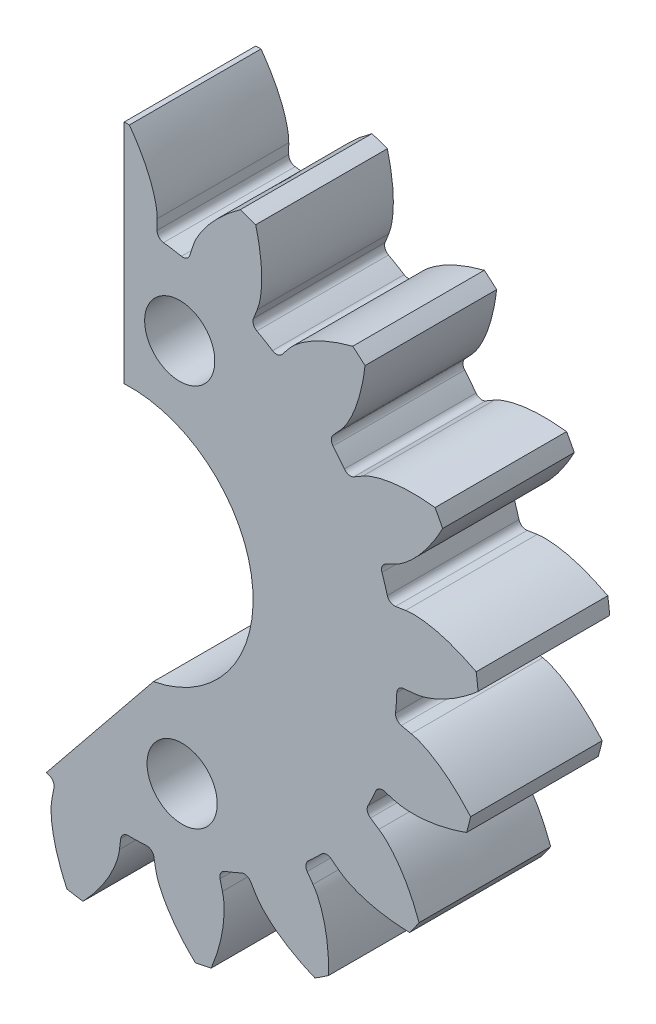
from build123d import *

# Parameters (mm, degrees)
SKETCH1_R                                           = 1.5
BOSS_EXTRUDE1_DEPTH                                 = 4.5
CUT_EXTRUDE1_DEPTH                                  = 5.5000001
CSK_FOR_M2_COUNTERSUNK_FLAT_HEAD_SCREW1_D           = 2.4
CSK_FOR_M2_COUNTERSUNK_FLAT_HEAD_SCREW1_DEPTH       = 10
CSK_FOR_M2_COUNTERSUNK_FLAT_HEAD_SCREW1_CSINK_D     = 4.4
CSK_FOR_M2_COUNTERSUNK_FLAT_HEAD_SCREW1_CSINK_ANGLE = 90
CSK_FOR_M2_COUNTERSUNK_FLAT_HEAD_SCREW1_TIP         = 0.721032743


with BuildPart() as part:
    # Sketch1 → Boss-Extrude1 (new body)
    with BuildSketch(Plane.XY):
        with BuildLine():
            Line((2.142690816, 9.446385822), (2.036760212, 9.116523343))
            ThreePointArc((2.036760212, 9.116523343), (1.925215556, 8.976884922), (1.749077663, 8.946610489))
            ThreePointArc((1.749077663, 8.946610489), (1.443445404, 9.000976463), (1.136139278, 9.044904613))
            ThreePointArc((1.136139278, 9.044904613), (0.978300237, 9.128737399), (0.916012393, 9.296252542))
            Line((0.916012393, 9.296252542), (0.918538131, 9.642697586))
            add(Edge.make_bspline(
                [(0.918538131, 9.642697586), (0.920074647, 9.853455045), (0.756738592, 10.686258414), (0.336577813, 11.434986659), (-0.030409782, 11.94504001)],
                knots=[0, 0, 0, 0, 0.250058326, 1, 1, 1, 1], degree=3))
            ThreePointArc((-0.030409782, 11.94504001), (-0.308005832, 11.941107068), (-0.585435504, 11.93072382))
            add(Edge.make_bspline(
                [(-0.585435504, 11.93072382), (-0.924729077, 11.407724954), (-1.308534817, 10.639195503), (-1.429406641, 9.798416791), (-1.414428472, 9.582521648)],
                knots=[-0.008484668, -0.008484668, -0.008484668, -0.008484668, 0.741457006, 1, 1, 1, 1], degree=3))
            Line((-1.414428472, 9.582521648), (-1.394045746, 9.236667499))
            ThreePointArc((-1.394045746, 9.236667499), (-1.447614825, 9.066163972), (-1.600922132, 8.974305558))
            ThreePointArc((-1.600922132, 8.974305558), (-1.905554981, 8.914593212), (-2.207978087, 8.844543215))
            ThreePointArc((-2.207978087, 8.844543215), (-2.385442505, 8.865696922), (-2.50403764, 8.999399176))
            Line((-2.50403764, 8.999399176), (-2.626832843, 9.32336196))
            add(Edge.make_bspline(
                [(-2.626832843, 9.32336196), (-2.701534461, 9.520442492), (-3.154684073, 10.238004717), (-3.81694417, 10.784393433), (-4.343402434, 11.127432808)],
                knots=[0, 0, 0, 0, 0.250058326, 1, 1, 1, 1], degree=3))
            ThreePointArc((-4.343402434, 11.127432808), (-4.600832298, 11.023486189), (-4.855776901, 10.913584942))
            add(Edge.make_bspline(
                [(-4.855776901, 10.913584942), (-4.983229754, 10.303336047), (-5.063493088, 9.448057053), (-4.872478404, 8.620390313), (-4.780521357, 8.424484826)],
                knots=[-0.008484668, -0.008484668, -0.008484668, -0.008484668, 0.741457006, 1, 1, 1, 1], degree=3))
            Line((-4.780521357, 8.424484826), (-4.636578102, 8.109348527))
            ThreePointArc((-4.636578102, 8.109348527), (-4.624936802, 7.93100734), (-4.734708522, 7.789970933))
            ThreePointArc((-4.734708522, 7.789970933), (-4.997199607, 7.62424475), (-5.253895777, 7.449677247))
            ThreePointArc((-5.253895777, 7.449677247), (-5.427018018, 7.405294949), (-5.585903513, 7.487127083))
            Line((-5.585903513, 7.487127083), (-5.817435487, 7.74485464))
            add(Edge.make_bspline(
                [(-5.817435487, 7.74485464), (-5.95828637, 7.901641426), (-6.640049173, 8.407051753), (-7.454966693, 8.677308116), (-8.069794519, 8.807004146)],
                knots=[0, 0, 0, 0, 0.250058326, 1, 1, 1, 1], degree=3))
            ThreePointArc((-8.069794519, 8.807004146), (-8.272290869, 8.617082417), (-8.470318721, 8.422505943))
            add(Edge.make_bspline(
                [(-8.470318721, 8.422505943), (-8.368717639, 7.807424515), (-8.13459856, 6.980906144), (-7.65749496, 6.278132356), (-7.500978342, 6.128674647)],
                knots=[-0.008484668, -0.008484668, -0.008484668, -0.008484668, 0.741457006, 1, 1, 1, 1], degree=3))
            Line((-7.500978342, 6.128674647), (-7.252914893, 5.886817101))
            ThreePointArc((-7.252914893, 5.886817101), (-7.177635437, 5.724724219), (-7.22904629, 5.553557567))
            ThreePointArc((-7.22904629, 5.553557567), (-7.413944735, 5.304199787), (-7.59024573, 5.048691086))
            ThreePointArc((-7.59024573, 5.048691086), (-7.735644677, 4.944766859), (-7.913362165, 4.963676991))
            Line((-7.913362165, 4.963676991), (-8.222361232, 5.120361784))
            add(Edge.make_bspline(
                [(-8.222361232, 5.120361784), (-8.410338689, 5.2156799), (-9.228638839, 5.440679864), (-10.086154654, 5.398304255), (-10.706316137, 5.297140773)],
                knots=[0, 0, 0, 0, 0.250058326, 1, 1, 1, 1], degree=3))
            ThreePointArc((-10.706316137, 5.297140773), (-10.826530719, 5.046893916), (-10.940897062, 4.793920846))
            add(Edge.make_bspline(
                [(-10.940897062, 4.793920846), (-10.623963835, 4.25707704), (-10.107081422, 3.570945177), (-9.40832439, 3.087977836), (-9.208386639, 3.005152997)],
                knots=[-0.008484668, -0.008484668, -0.008484668, -0.008484668, 0.741457006, 1, 1, 1, 1], degree=3))
            Line((-9.208386639, 3.005152997), (-8.889705338, 2.869238405))
            ThreePointArc((-8.889705338, 2.869238405), (-8.760954633, 2.745285371), (-8.7470613, 2.567105479))
            ThreePointArc((-8.7470613, 2.567105479), (-8.829395545, 2.267793252), (-8.901490937, 1.965851218))
            ThreePointArc((-8.901490937, 1.965851218), (-8.999529656, 1.816420605), (-9.172077407, 1.769854816))
            Line((-9.172077407, 1.769854816), (-9.516811531, 1.804335697))
            add(Edge.make_bspline(
                [(-9.516811531, 1.804335697), (-9.726528165, 1.825311903), (-10.570849691, 1.739514011), (-11.35515154, 1.390229491), (-11.896890436, 1.071869186)],
                knots=[0, 0, 0, 0, 0.250058326, 1, 1, 1, 1], degree=3))
            ThreePointArc((-11.896890436, 1.071869186), (-11.918587603, 0.795094426), (-11.933846629, 0.517890175))
            add(Edge.make_bspline(
                [(-11.933846629, 0.517890175), (-11.444384845, 0.131787721), (-10.714546932, -0.321291723), (-9.888507478, -0.519225201), (-9.672151294, -0.524231217)],
                knots=[-0.008484668, -0.008484668, -0.008484668, -0.008484668, 0.741457006, 1, 1, 1, 1], degree=3))
            Line((-9.672151294, -0.524231217), (-9.325891817, -0.535846836))
            ThreePointArc((-9.325891817, -0.535846836), (-9.16105836, -0.604919479), (-9.083737211, -0.766048429))
            ThreePointArc((-9.083737211, -0.766048429), (-9.052387561, -1.074891329), (-9.010540469, -1.382487749))
            ThreePointArc((-9.010540469, -1.382487749), (-9.047978288, -1.557243317), (-9.19205277, -1.662996058))
            Line((-9.19205277, -1.662996058), (-9.525963699, -1.755375925))
            add(Edge.make_bspline(
                [(-9.525963699, -1.755375925), (-9.729096116, -1.811574581), (-10.485408718, -2.196582847), (-11.090572289, -2.805603469), (-11.480723759, -3.298164274)],
                knots=[0, 0, 0, 0, 0.250058326, 1, 1, 1, 1], degree=3))
            ThreePointArc((-11.480723759, -3.298164274), (-11.400973189, -3.564086973), (-11.315064081, -3.828084435))
            add(Edge.make_bspline(
                [(-11.315064081, -3.828084435), (-10.719178266, -4.01130026), (-9.874953507, -4.170136395), (-9.033192836, -4.056303998), (-8.829638322, -3.982815101)],
                knots=[-0.008484668, -0.008484668, -0.008484668, -0.008484668, 0.741457006, 1, 1, 1, 1], degree=3))
            Line((-8.829638322, -3.982815101), (-8.50256493, -3.868562992))
            ThreePointArc((-8.50256493, -3.868562992), (-8.323910392, -3.873426601), (-8.193604078, -3.995743252))
            ThreePointArc((-8.193604078, -3.995743252), (-8.052804476, -4.272405879), (-7.902666581, -4.544114086))
            ThreePointArc((-7.902666581, -4.544114086), (-7.874447315, -4.7205929), (-7.970590473, -4.8712501))
            Line((-7.970590473, -4.8712501), (-8.248581684, -5.078014301))
            add(Edge.make_bspline(
                [(-8.248581684, -5.078014301), (-8.417695725, -5.20379788), (-8.983855196, -5.836019021), (-9.328149796, -6.622524135), (-9.514021721, -7.222762373)],
                knots=[0, 0, 0, 0, 0.250058326, 1, 1, 1, 1], degree=3))
            ThreePointArc((-9.514021721, -7.222762373), (-9.34359417, -7.441918676), (-9.16811943, -7.657055029))
            add(Edge.make_bspline(
                [(-9.16811943, -7.657055029), (-8.546287266, -7.612639914), (-7.701692893, -7.45578104), (-6.957895448, -7.045556464), (-6.794633768, -6.903497736)],
                knots=[-0.008484668, -0.008484668, -0.008484668, -0.008484668, 0.741457006, 1, 1, 1, 1], degree=3))
            Line((-6.794633768, -6.903497736), (-6.530919535, -6.678808281))
            ThreePointArc((-6.530919535, -6.678808281), (-6.362572202, -6.618805997), (-6.196879311, -6.685790808))
            ThreePointArc((-6.196879311, -6.685790808), (-5.965645524, -6.892908341), (-5.727493781, -7.092032636))
            ThreePointArc((-5.727493781, -7.092032636), (-5.637428599, -7.246400254), (-5.672655765, -7.421614824))
            Line((-5.672655765, -7.421614824), (-5.857183005, -7.714838707))
            add(Edge.make_bspline(
                [(-5.857183005, -7.714838707), (-5.969438883, -7.893219439), (-6.268982248, -8.687268487), (-6.305908984, -9.545036219), (-6.26239833, -10.171886391)],
                knots=[0, 0, 0, 0, 0.250058326, 1, 1, 1, 1], degree=3))
            ThreePointArc((-6.26239833, -10.171886391), (-6.024310985, -10.314678025), (-5.782969448, -10.451897912))
            add(Edge.make_bspline(
                [(-5.782969448, -10.451897912), (-5.219172814, -10.185850364), (-4.488275976, -9.734481141), (-3.942895724, -9.083267488), (-3.841976273, -8.891824748)],
                knots=[-0.008484668, -0.008484668, -0.008484668, -0.008484668, 0.741457006, 1, 1, 1, 1], degree=3))
            Line((-3.841976273, -8.891824748), (-3.677237268, -8.587043502))
            ThreePointArc((-3.677237268, -8.587043502), (-3.541933379, -8.470278967), (-3.363231656, -8.472885267))
            ThreePointArc((-3.363231656, -8.472885267), (-3.072793087, -8.582485337), (-2.778791209, -8.682132879))
            ThreePointArc((-2.778791209, -8.682132879), (-2.639043912, -8.7935411), (-2.608597463, -8.969649341))
            Line((-2.608597463, -8.969649341), (-2.674739306, -9.309731396))
            add(Edge.make_bspline(
                [(-2.674739306, -9.309731396), (-2.714976241, -9.516617976), (-2.70744851, -10.365254206), (-2.432020221, -11.178438271), (-2.165003344, -11.747240788)],
                knots=[0, 0, 0, 0, 0.250058326, 1, 1, 1, 1], degree=3))
            ThreePointArc((-2.165003344, -11.747240788), (-1.891411218, -11.794382951), (-1.616797397, -11.835154067))
            add(Edge.make_bspline(
                [(-1.616797397, -11.835154067), (-1.187180152, -11.38340528), (-0.668692519, -10.698485624), (-0.395386084, -9.894232906), (-0.370438593, -9.679261556)],
                knots=[-0.008484668, -0.008484668, -0.008484668, -0.008484668, 0.741457006, 1, 1, 1, 1], degree=3))
            Line((-0.370438593, -9.679261556), (-0.326923731, -9.335550916))
            ThreePointArc((-0.326923731, -9.335550916), (-0.242936827, -9.177793828), (-0.075360929, -9.115669622))
            ThreePointArc((-0.075360929, -9.115669622), (0.235057082, -9.112950131), (0.545202514, -9.099662968))
            ThreePointArc((0.545202514, -9.099662968), (0.715758279, -9.153065494), (0.807766381, -9.306283012))
            Line((0.807766381, -9.306283012), (0.868942758, -9.647293274))
            add(Edge.make_bspline(
                [(0.868942758, -9.647293274), (0.906158986, -9.854744521), (1.219741152, -10.643354909), (1.770326349, -11.302130292), (2.22478734, -11.736065222)],
                knots=[0, 0, 0, 0, 0.250058326, 1, 1, 1, 1], degree=3))
            ThreePointArc((2.22478734, -11.736065222), (2.496934113, -11.681191105), (2.767732101, -11.620007083))
            add(Edge.make_bspline(
                [(2.767732101, -11.620007083), (3.005147767, -11.043568236), (3.241201568, -10.217600341), (3.205522637, -9.368927344), (3.151128871, -9.159460457)],
                knots=[-0.008484668, -0.008484668, -0.008484668, -0.008484668, 0.741457006, 1, 1, 1, 1], degree=3))
            Line((3.151128871, -9.159460457), (3.067542667, -8.823240448))
            ThreePointArc((3.067542667, -8.823240448), (3.08886969, -8.645796776), (3.222687709, -8.527332282))
            ThreePointArc((3.222687709, -8.527332282), (3.511161491, -8.412660513), (3.795563616, -8.288233151))
            ThreePointArc((3.795563616, -8.288233151), (3.973893348, -8.276417674), (4.115036899, -8.386051594))
            Line((4.115036899, -8.386051594), (4.295269287, -8.681934737))
            add(Edge.make_bspline(
                [(4.295269287, -8.681934737), (4.40491242, -8.861933212), (4.982198012, -9.484011554), (5.733580536, -9.899406991), (6.314108166, -10.139869016)],
                knots=[0, 0, 0, 0, 0.250058326, 1, 1, 1, 1], degree=3))
            ThreePointArc((6.314108166, -10.139869016), (6.548054657, -9.990389672), (6.778464043, -9.835513755))
            add(Edge.make_bspline(
                [(6.778464043, -9.835513755), (6.791613828, -9.212236107), (6.713353424, -8.356771514), (6.373507764, -7.578296229), (6.247118921, -7.402623469)],
                knots=[-0.008484668, -0.008484668, -0.008484668, -0.008484668, 0.741457006, 1, 1, 1, 1], degree=3))
            Line((6.247118921, -7.402623469), (6.047720431, -7.119302467))
            ThreePointArc((6.047720431, -7.119302467), (6.003507239, -6.946136961), (6.085494515, -6.787331466))
            ThreePointArc((6.085494515, -6.787331466), (6.313064084, -6.576194476), (6.53331282, -6.357431519))
            ThreePointArc((6.53331282, -6.357431519), (6.6953321, -6.281993786), (6.866548882, -6.33323744))
            Line((6.866548882, -6.33323744), (7.141495898, -6.544032806))
            add(Edge.make_bspline(
                [(7.141495898, -6.544032806), (7.308758024, -6.672268717), (8.071781424, -7.043799887), (8.9224829, -7.159713921), (9.550673697, -7.174227313)],
                knots=[0, 0, 0, 0, 0.250058326, 1, 1, 1, 1], degree=3))
            ThreePointArc((9.550673697, -7.174227313), (9.714824136, -6.950330756), (9.873726855, -6.722679793))
            add(Edge.make_bspline(
                [(9.873726855, -6.722679793), (9.660834808, -6.136740445), (9.278829699, -5.367314387), (8.68071535, -4.764174216), (8.499400943, -4.646021162)],
                knots=[-0.008484668, -0.008484668, -0.008484668, -0.008484668, 0.741457006, 1, 1, 1, 1], degree=3))
            Line((8.499400943, -4.646021162), (8.211120038, -4.453863238))
            ThreePointArc((8.211120038, -4.453863238), (8.107337868, -4.30836286), (8.126421565, -4.130663926))
            ThreePointArc((8.126421565, -4.130663926), (8.262352391, -3.851576936), (8.388701925, -3.568023533))
            ThreePointArc((8.388701925, -3.568023533), (8.512529152, -3.439151827), (8.69069539, -3.425084476))
            Line((8.69069539, -3.425084476), (9.023223916, -3.522322983))
            add(Edge.make_bspline(
                [(9.023223916, -3.522322983), (9.225515358, -3.58147736), (10.071226027, -3.652284013), (10.906354508, -3.453061812), (11.497367823, -3.239666457)],
                knots=[0, 0, 0, 0, 0.250058326, 1, 1, 1, 1], degree=3))
            ThreePointArc((11.497367823, -3.239666457), (11.569552783, -2.971591157), (11.635488142, -2.701910674))
            add(Edge.make_bspline(
                [(11.635488142, -2.701910674), (11.225306515, -2.232443981), (10.591148608, -1.652971712), (9.815544227, -1.306624075), (9.603791772, -1.261947952)],
                knots=[-0.008484668, -0.008484668, -0.008484668, -0.008484668, 0.741457006, 1, 1, 1, 1], degree=3))
            Line((9.603791772, -1.261947952), (9.265562385, -1.186905099))
            ThreePointArc((9.265562385, -1.186905099), (9.116227595, -1.088720481), (9.069830353, -0.916127333))
            ThreePointArc((9.069830353, -0.916127333), (9.095764224, -0.606782588), (9.111150352, -0.296734198))
            ThreePointArc((9.111150352, -0.296734198), (9.180061972, -0.131833357), (9.341115328, -0.054354874))
            Line((9.341115328, -0.054354874), (9.686315544, -0.024903923))
            add(Edge.make_bspline(
                [(9.686315544, -0.024903923), (9.896315722, -0.006987639), (10.710495748, 0.232493054), (11.417262505, 0.719945428), (11.891278715, 1.132429305)],
                knots=[0, 0, 0, 0, 0.250058326, 1, 1, 1, 1], degree=3))
            ThreePointArc((11.891278715, 1.132429305), (11.861749218, 1.408478293), (11.825812282, 1.683766454))
            add(Edge.make_bspline(
                [(11.825812282, 1.683766454), (11.273738375, 1.973356413), (10.47307421, 2.284613953), (9.624729466, 2.327392886), (9.411137305, 2.292558321)],
                knots=[-0.008484668, -0.008484668, -0.008484668, -0.008484668, 0.741457006, 1, 1, 1, 1], degree=3))
            Line((9.411137305, 2.292558321), (9.068639189, 2.24035115))
            ThreePointArc((9.068639189, 2.24035115), (8.89392027, 2.277959631), (8.788308294, 2.422137332))
            ThreePointArc((8.788308294, 2.422137332), (8.700742697, 2.719961111), (8.603087437, 3.014630735))
            ThreePointArc((8.603087437, 3.014630735), (8.607776555, 3.193289938), (8.72996588, 3.323715655))
            Line((8.72996588, 3.323715655), (9.041216585, 3.47587855))
            add(Edge.make_bspline(
                [(9.041216585, 3.47587855), (9.23056381, 3.568445801), (9.90325367, 4.085870646), (10.386205936, 4.795720049), (10.679206525, 5.351584215)],
                knots=[0, 0, 0, 0, 0.250058326, 1, 1, 1, 1], degree=3))
            ThreePointArc((10.679206525, 5.351584215), (10.551950692, 5.598324945), (10.418994944, 5.842041592))
            add(Edge.make_bspline(
                [(10.418994944, 5.842041592), (9.799589398, 5.912644088), (8.940553107, 5.913649844), (8.134041659, 5.647082543), (7.947456596, 5.537441889)],
                knots=[-0.008484668, -0.008484668, -0.008484668, -0.008484668, 0.741457006, 1, 1, 1, 1], degree=3))
            Line((7.947456596, 5.537441889), (7.64694602, 5.365035562))
            ThreePointArc((7.64694602, 5.365035562), (7.470439729, 5.336988673), (7.319876502, 5.433278929))
            ThreePointArc((7.319876502, 5.433278929), (7.130637656, 5.67935899), (6.933129893, 5.918853082))
            ThreePointArc((6.933129893, 5.918853082), (6.872963217, 6.087141733), (6.939786166, 6.252899967))
            Line((6.939786166, 6.252899967), (7.175051226, 6.507224364))
            add(Edge.make_bspline(
                [(7.175051226, 6.507224364), (7.318173108, 6.661940862), (7.758522308, 7.387428767), (7.952434703, 8.223806103), (8.024848318, 8.847978022)],
                knots=[0, 0, 0, 0, 0.250058326, 1, 1, 1, 1], degree=3))
            ThreePointArc((8.024848318, 8.847978022), (7.817052756, 9.032086792), (7.605034605, 9.211316641))
            add(Edge.make_bspline(
                [(7.605034605, 9.211316641), (7.001951571, 9.053396417), (6.200560765, 8.744014555), (5.544806453, 8.20410241), (5.410427836, 8.034463247)],
                knots=[-0.008484668, -0.008484668, -0.008484668, -0.008484668, 0.741457006, 1, 1, 1, 1], degree=3))
            Line((5.410427836, 8.034463247), (5.192490418, 7.765142193))
            ThreePointArc((5.192490418, 7.765142193), (5.038034908, 7.675227821), (4.862854828, 7.710626099))
            ThreePointArc((4.862854828, 7.710626099), (4.597500488, 7.871727967), (4.326814738, 8.023701524))
            ThreePointArc((4.326814738, 8.023701524), (4.209918111, 8.158891306), (4.212349875, 8.33759549))
            Line((4.212349875, 8.33759549), (4.339855442, 8.65973347))
            add(Edge.make_bspline(
                [(4.339855442, 8.65973347), (4.417422576, 8.855703895), (4.565959517, 9.691273698), (4.444643097, 10.541221574), (4.286689878, 11.149403369)],
                knots=[0, 0, 0, 0, 0.250058326, 1, 1, 1, 1], degree=3))
            ThreePointArc((4.286689878, 11.149403369), (4.026418528, 11.246015269), (3.763972202, 11.336552336))
            add(Edge.make_bspline(
                [(3.763972202, 11.336552336), (3.258661385, 10.971437393), (2.623148333, 10.393451648), (2.206714411, 9.653112786), (2.142690816, 9.446385822)],
                knots=[-0.008484668, -0.008484668, -0.008484668, -0.008484668, 0.741457006, 1, 1, 1, 1], degree=3))
        make_face()
        Circle(SKETCH1_R, mode=Mode.SUBTRACT)
    extrude(amount=BOSS_EXTRUDE1_DEPTH)

    # Sketch4 → Cut-Extrude1 (cut, through all)
    with BuildSketch(Plane(origin=(0, 0, 0), x_dir=(-1, 0, 0), z_dir=(0, 0, -1))):
        with BuildLine():
            Line((12.86321323, 15.189801976), (0.209946094, 15.189801976))
            Line((0.209946094, 15.189801976), (0.209946094, 4.194749413))
            ThreePointArc((0.209946094, 4.194749413), (-4.169900225, 0.501928397), (-0.791467324, -4.12475205))
            Line((-0.791467324, -4.12475205), (2.872793087, -8.653266145))
            Line((2.872793087, -8.653266145), (2.872793087, -14.49172888))
            Line((2.872793087, -14.49172888), (12.86321323, -14.49172888))
            Line((12.86321323, -14.49172888), (12.86321323, 15.189801976))
        make_face()
    extrude(amount=-CUT_EXTRUDE1_DEPTH, mode=Mode.SUBTRACT)

    # CSK for M2 Countersunk Flat Head Screw1
    with Locations(Plane(origin=(0, 0, 0), x_dir=(1, 0, 0), z_dir=(0, 0, -1))):
        with Locations((1.690053906, -6.412399978), (1.772781001, 6.658395059)):
            CounterSinkHole(CSK_FOR_M2_COUNTERSUNK_FLAT_HEAD_SCREW1_D / 2, CSK_FOR_M2_COUNTERSUNK_FLAT_HEAD_SCREW1_CSINK_D / 2, depth=CSK_FOR_M2_COUNTERSUNK_FLAT_HEAD_SCREW1_DEPTH, counter_sink_angle=CSK_FOR_M2_COUNTERSUNK_FLAT_HEAD_SCREW1_CSINK_ANGLE)
            with Locations((0, 0, -(CSK_FOR_M2_COUNTERSUNK_FLAT_HEAD_SCREW1_DEPTH + CSK_FOR_M2_COUNTERSUNK_FLAT_HEAD_SCREW1_TIP / 2))):  # 118° drill point
                Cone(0, CSK_FOR_M2_COUNTERSUNK_FLAT_HEAD_SCREW1_D / 2, CSK_FOR_M2_COUNTERSUNK_FLAT_HEAD_SCREW1_TIP, mode=Mode.SUBTRACT)


solid = part.part
